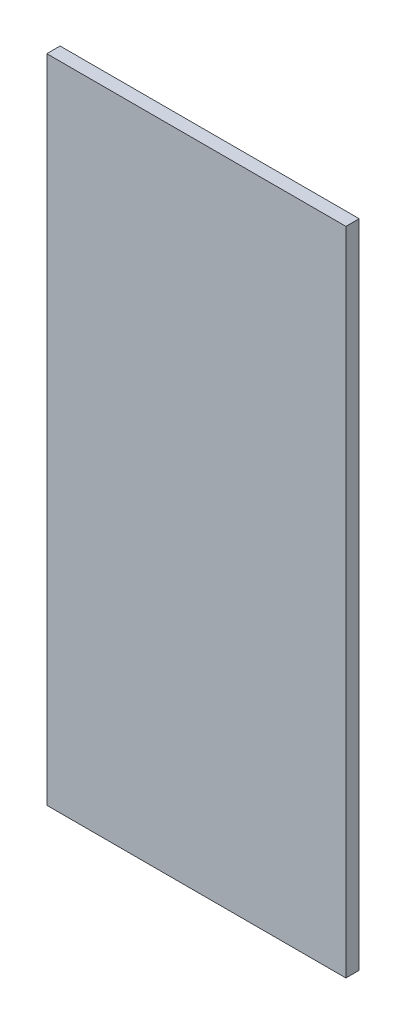
from build123d import *

# Parameters (mm, degrees)
SKETCH1_W           = 90
SKETCH1_H           = 195.870771436
BOSS_EXTRUDE1_DEPTH = 4


with BuildPart() as part:
    # Sketch1 → Boss-Extrude1 (new body)
    with BuildSketch(Plane.XY):
        with Locations((25.95, 297.01464127)):
            Rectangle(SKETCH1_W, SKETCH1_H)
    extrude(amount=BOSS_EXTRUDE1_DEPTH)


solid = part.part
